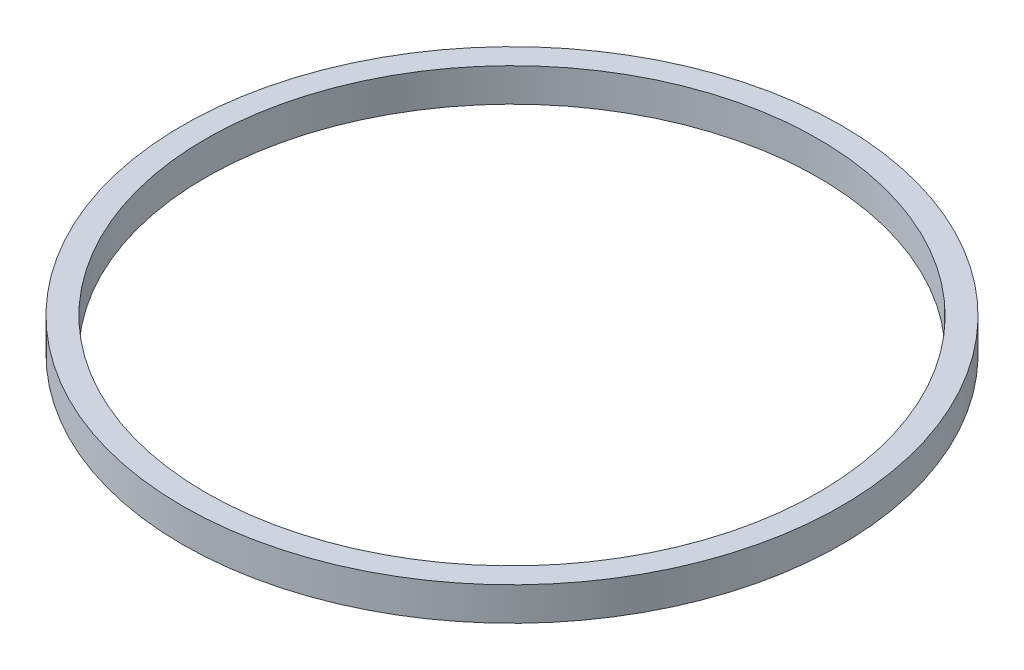
from build123d import *

# Parameters (mm, degrees)
SKETCH3_R           = 1079.5
SKETCH3_R_2         = 1003.3
BOSS_EXTRUDE2_DEPTH = 109.22


with BuildPart() as part:
    # Sketch3 → Boss-Extrude2 (new body)
    with BuildSketch(Plane(origin=(0, 0, 0), x_dir=(1, 0, 0), z_dir=(0, 1, 0))):
        Circle(SKETCH3_R)
        Circle(SKETCH3_R_2, mode=Mode.SUBTRACT)
    extrude(amount=BOSS_EXTRUDE2_DEPTH)


solid = part.part
